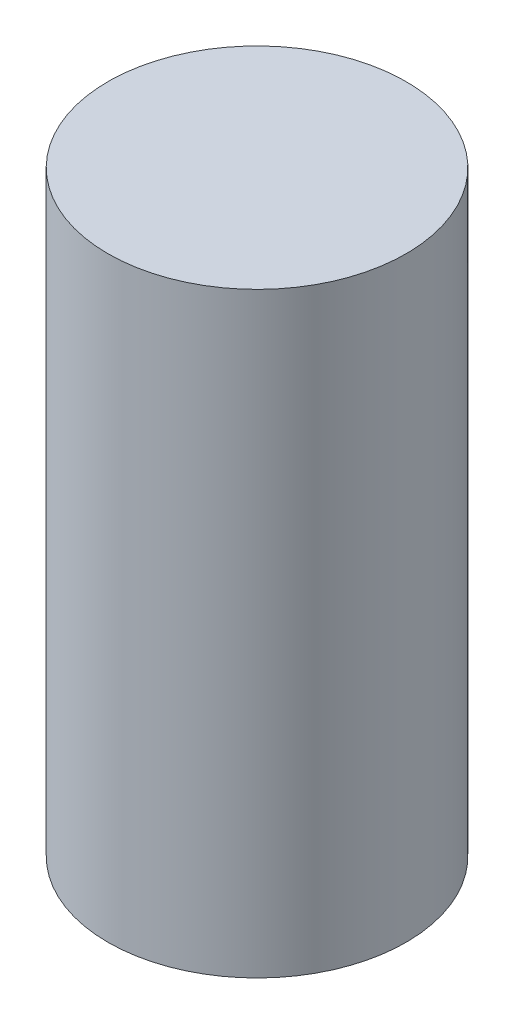
from build123d import *

# Parameters (mm, degrees)
SKETCH2_R           = 15
BOSS_EXTRUDE1_DEPTH = 60


with BuildPart() as part:
    # Sketch2 → Boss-Extrude1 (new body)
    with BuildSketch(Plane(origin=(0, 0, 0), x_dir=(1, 0, 0), z_dir=(0, 1, 0))):
        Circle(SKETCH2_R)
    extrude(amount=BOSS_EXTRUDE1_DEPTH)


solid = part.part
